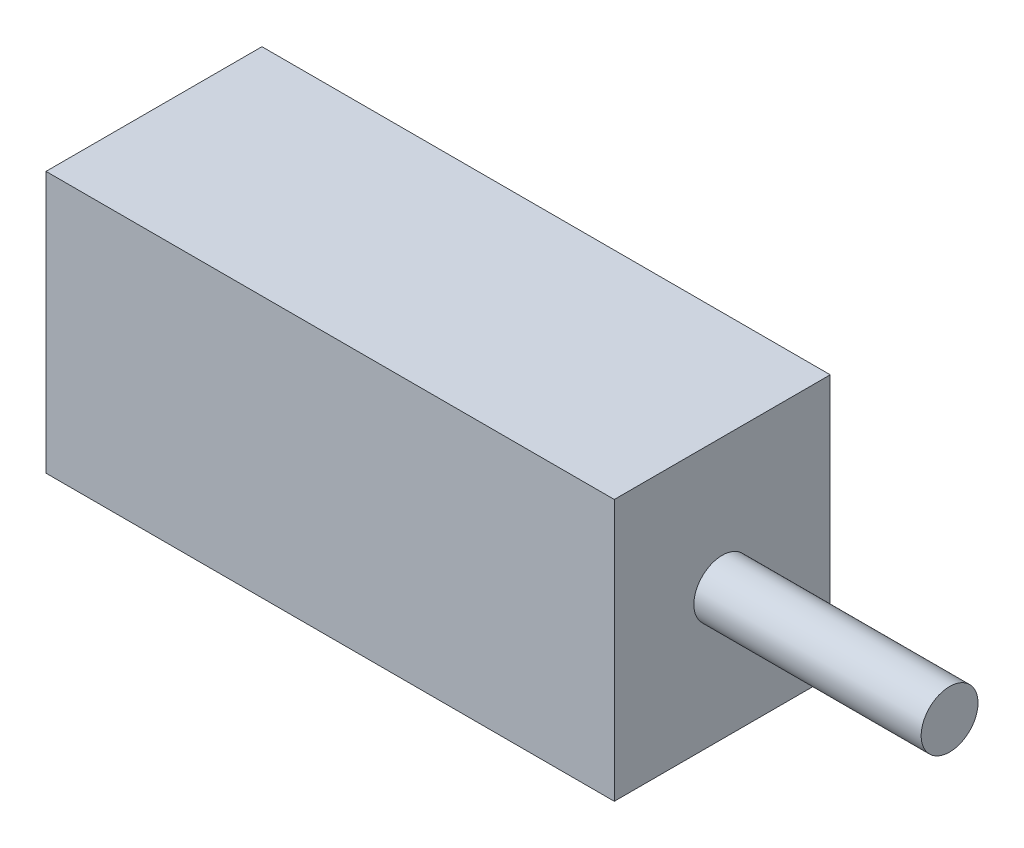
from build123d import *

# Parameters (mm, degrees)
SKETCH1_R           = 1.25
BOSS_EXTRUDE1_DEPTH = 10
SKETCH2_W           = 9.5
SKETCH2_H           = 11.5
BOSS_EXTRUDE2_DEPTH = 25


with BuildPart() as part:
    # Sketch1 → Boss-Extrude1 (new body)
    with BuildSketch(Plane(origin=(0, 0, 0), x_dir=(0, 0, -1), z_dir=(1, 0, 0))):
        Circle(SKETCH1_R)
    extrude(amount=BOSS_EXTRUDE1_DEPTH)

    # Sketch2 → Boss-Extrude2 (add)
    with BuildSketch(Plane.ZY):
        Rectangle(SKETCH2_W, SKETCH2_H)
    extrude(amount=BOSS_EXTRUDE2_DEPTH)


solid = part.part
